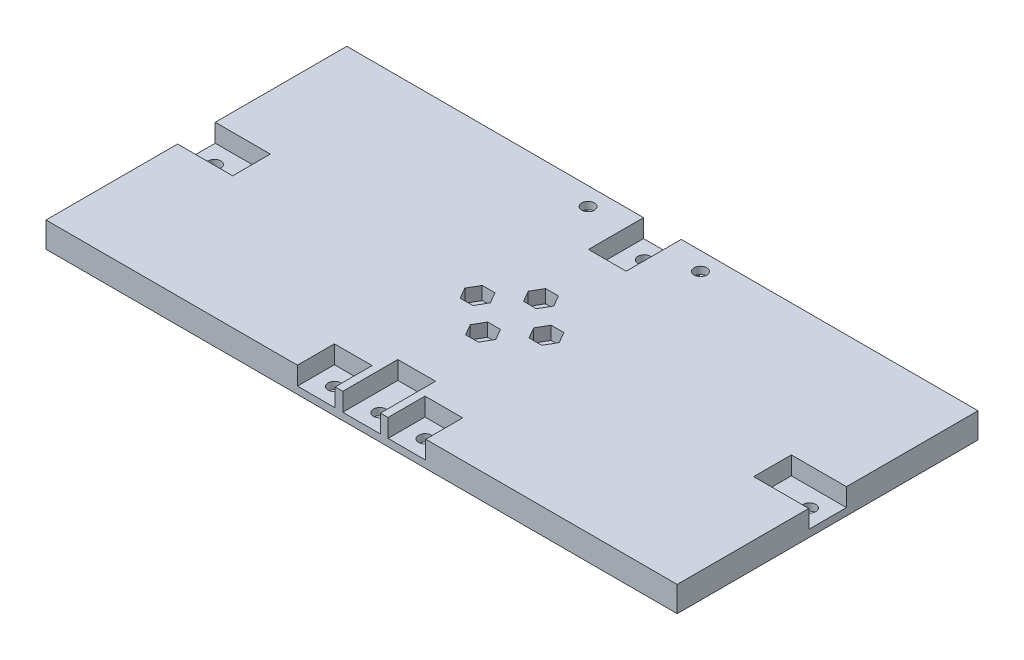
from build123d import *

# Parameters (mm, degrees)
SKETCH1_W           = 174.17
SKETCH1_H           = 83
BOSS_EXTRUDE1_DEPTH = 7
SKETCH2_R           = 1.75
CUT_EXTRUDE1_DEPTH  = 8
SKETCH3_R           = 1.75
CUT_EXTRUDE2_DEPTH  = 8
SKETCH4_W           = 15.4
SKETCH4_H           = 10.4
SKETCH4_W_2         = 10.4
SKETCH4_H_2         = 15.4
CUT_EXTRUDE3_DEPTH  = 5
SKETCH5_W           = 10.4
SKETCH5_H           = 10.4
CUT_EXTRUDE4_DEPTH  = 5
SKETCH6_R           = 1.75
CUT_EXTRUDE5_DEPTH  = 3
CUT_EXTRUDE6_DEPTH  = 3.64
SKETCH9_W           = 10.4
SKETCH9_H           = 10.4
CUT_EXTRUDE7_DEPTH  = 5
SKETCH10_R          = 1.75
CUT_EXTRUDE8_DEPTH  = 3


with BuildPart() as part:
    # Sketch1 → Boss-Extrude1 (new body)
    with BuildSketch(Plane(origin=(0, 0, 0), x_dir=(1, 0, 0), z_dir=(0, 1, 0))):
        with Locations((87.085, 41.5)):
            Rectangle(SKETCH1_W, SKETCH1_H)
    extrude(amount=BOSS_EXTRUDE1_DEPTH)

    # Sketch2 → Cut-Extrude1 (cut, through all)
    with BuildSketch(Plane(origin=(0, 7, 0), x_dir=(1, 0, 0), z_dir=(0, 1, 0))):
        with Locations((87.085, 49.5)):
            Circle(SKETCH2_R)
        with Locations((77.585, 41.5)):
            Circle(SKETCH2_R)
        with Locations((96.585, 41.5)):
            Circle(SKETCH2_R)
        with Locations((87.085, 33.5)):
            Circle(SKETCH2_R)
    extrude(amount=-CUT_EXTRUDE1_DEPTH, mode=Mode.SUBTRACT)

    # Sketch3 → Cut-Extrude2 (cut, through all)
    with BuildSketch(Plane(origin=(0, 7, 0), x_dir=(1, 0, 0), z_dir=(0, 1, 0))):
        with Locations((87.085, 78)):
            Circle(SKETCH3_R)
        with Locations((5, 41.5)):
            Circle(SKETCH3_R)
        with Locations((87.085, 5)):
            Circle(SKETCH3_R)
        with Locations((169.17, 41.5)):
            Circle(SKETCH3_R)
    extrude(amount=-CUT_EXTRUDE2_DEPTH, mode=Mode.SUBTRACT)

    # Sketch4 → Cut-Extrude3 (cut)
    with BuildSketch(Plane(origin=(0, 7, 0), x_dir=(1, 0, 0), z_dir=(0, 1, 0))):
        with Locations((7.5, 41.5)):
            Rectangle(SKETCH4_W, SKETCH4_H)
        with Locations((87.085, 7.5)):
            Rectangle(SKETCH4_W_2, SKETCH4_H_2)
        with Locations((87.085, 75.5)):
            Rectangle(SKETCH4_W_2, SKETCH4_H_2)
        with Locations((166.67, 41.5)):
            Rectangle(SKETCH4_W, SKETCH4_H)
    extrude(amount=-CUT_EXTRUDE3_DEPTH, mode=Mode.SUBTRACT)

    # Sketch5 → Cut-Extrude4 (cut)
    with BuildSketch(Plane(origin=(0, 7, 0), x_dir=(1, 0, 0), z_dir=(0, 1, 0))):
        with Locations((74.585, 5)):
            Rectangle(SKETCH5_W, SKETCH5_H)
        with Locations((99.585, 5)):
            Rectangle(SKETCH5_W, SKETCH5_H)
    extrude(amount=-CUT_EXTRUDE4_DEPTH, mode=Mode.SUBTRACT)

    # Sketch6 → Cut-Extrude5 (cut, through all)
    with BuildSketch(Plane(origin=(0, 2, 0), x_dir=(1, 0, 0), z_dir=(0, 1, 0))):
        with Locations((74.585, 5)):
            Circle(SKETCH6_R)
        with Locations((99.585, 5)):
            Circle(SKETCH6_R)
    extrude(amount=-CUT_EXTRUDE5_DEPTH, mode=Mode.SUBTRACT)

    # Sketch7 → Cut-Extrude6 (cut)
    with BuildSketch(Plane(origin=(0, 7, 0), x_dir=(1, 0, 0), z_dir=(0, 1, 0))):
        Polygon((75.824081679, 44.55), (79.345918321, 44.55), (81.106836642, 41.5), (79.345918321, 38.45), (75.824081679, 38.45), (74.063163358, 41.5), align=None)
        Polygon((85.324081679, 52.55), (88.845918321, 52.55), (90.606836642, 49.5), (88.845918321, 46.45), (85.324081679, 46.45), (83.563163358, 49.5), align=None)
        Polygon((100.106836642, 41.5), (98.345918321, 44.55), (94.824081679, 44.55), (93.063163358, 41.5), (94.824081679, 38.45), (98.345918321, 38.45), align=None)
        Polygon((83.563163358, 33.5), (85.324081679, 30.45), (88.845918321, 30.45), (90.606836642, 33.5), (88.845918321, 36.55), (85.324081679, 36.55), align=None)
    extrude(amount=-CUT_EXTRUDE6_DEPTH, mode=Mode.SUBTRACT)

    # Sketch9 → Cut-Extrude7 (cut)
    with BuildSketch(Plane.XZ):
        with Locations((71.585, -78)):
            Rectangle(SKETCH9_W, SKETCH9_H)
        with Locations((102.585, -78)):
            Rectangle(SKETCH9_W, SKETCH9_H)
    extrude(amount=-CUT_EXTRUDE7_DEPTH, mode=Mode.SUBTRACT)

    # Sketch10 → Cut-Extrude8 (cut, through all)
    with BuildSketch(Plane.XZ.offset(-5)):
        with Locations((71.585, -78)):
            Circle(SKETCH10_R)
        with Locations((102.585, -78)):
            Circle(SKETCH10_R)
    extrude(amount=-CUT_EXTRUDE8_DEPTH, mode=Mode.SUBTRACT)


solid = part.part
